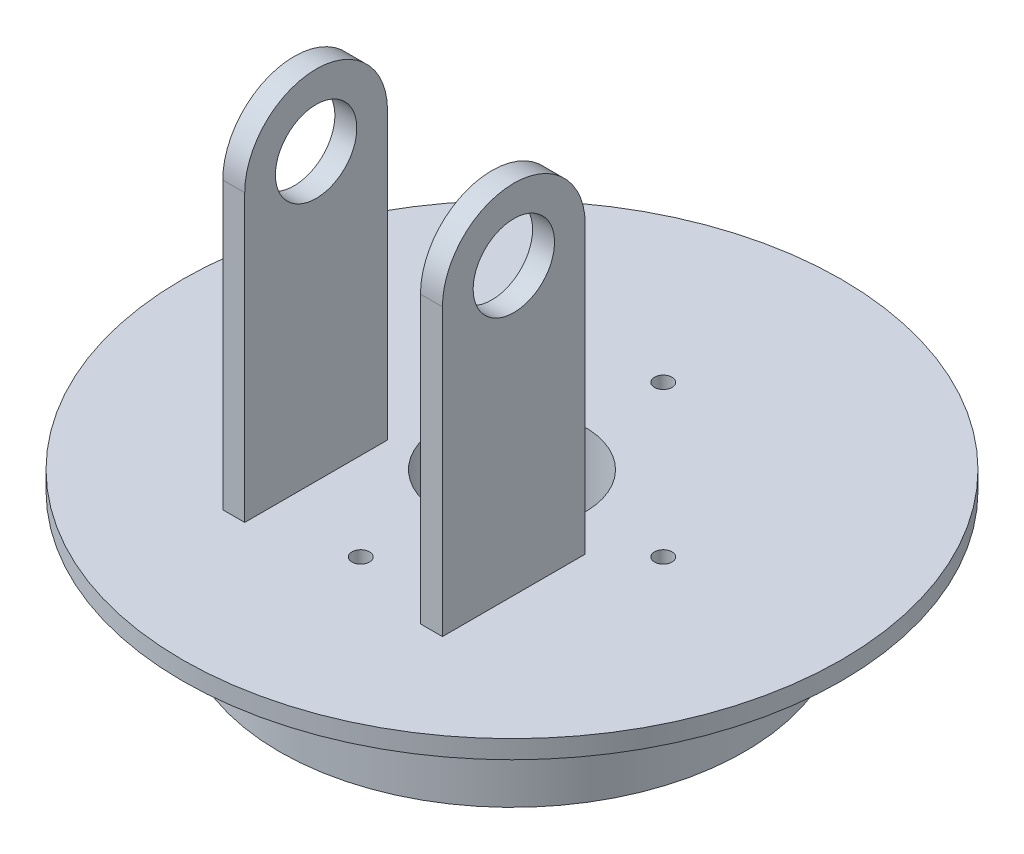
from build123d import *

# Parameters (mm, degrees)
SKETCH_1_R          = 90
EXTRUDE_2_DEPTH     = 5
SKETCH_2_R          = 63.5
EXTRUDE_3_DEPTH     = 30
SKETCH_3_R          = 2.415
CUT_EXTRUDE_1_DEPTH = 36
SKETCH_4_W          = 6
SKETCH_4_H          = 39
EXTRUDE_4_DEPTH     = 78
EXTRUDE_START       = -6
EXTRUDE_5_DEPTH     = 6
EXTRUDE_6_DEPTH     = 6
SKETCH_8_R          = 11.1125
CUT_EXTRUDE_3_DEPTH = 121
SKETCH2_R           = 20
CUT_EXTRUDE1_DEPTH  = 36


with BuildPart() as part:
    # 草圖1 → 填料-伸長2 (new body)
    with BuildSketch(Plane(origin=(0, 0, 0), x_dir=(1, 0, 0), z_dir=(0, 1, 0))):
        Circle(SKETCH_1_R)
    extrude(amount=EXTRUDE_2_DEPTH)

    # 草圖2 → 填料-伸長3 (add)
    with BuildSketch(Plane.XZ):
        Circle(SKETCH_2_R)
    extrude(amount=EXTRUDE_3_DEPTH)

    # 草圖3 → 除料-伸長1 (cut, through all)
    with BuildSketch(Plane(origin=(0, 5, 0), x_dir=(1, 0, 0), z_dir=(0, 1, 0))):
        with Locations((0, 41.31)):
            Circle(SKETCH_3_R)
        with Locations((0, -41.31)):
            Circle(SKETCH_3_R)
        with Locations((-41.31, 0)):
            Circle(SKETCH_3_R)
        with Locations((41.31, 0)):
            Circle(SKETCH_3_R)
    extrude(amount=-CUT_EXTRUDE_1_DEPTH, mode=Mode.SUBTRACT)

    # 草圖4 → 填料-伸長4 (add)
    with BuildSketch(Plane(origin=(0, 5, 0), x_dir=(1, 0, 0), z_dir=(0, 1, 0))):
        with Locations((-27, -29.5)):
            Rectangle(SKETCH_4_W, SKETCH_4_H)
        with Locations((27, -29.5)):
            Rectangle(SKETCH_4_W, SKETCH_4_H)
    extrude(amount=EXTRUDE_4_DEPTH)

    # 草圖5 → 填料-伸長5 (add)
    with BuildSketch(Plane.ZY.offset(30).offset(EXTRUDE_START)):
        with BuildLine():
            Line((10, 83), (49, 83))
            ThreePointArc((49, 83), (29.5, 102.5), (10, 83))
        make_face()
    extrude(amount=EXTRUDE_5_DEPTH)

    # 草圖7 → 填料-伸長6 (add)
    with BuildSketch(Plane.ZY.offset(-24)):
        with BuildLine():
            Line((10, 83), (49, 83))
            ThreePointArc((49, 83), (29.5, 102.5), (10, 83))
        make_face()
    extrude(amount=-EXTRUDE_6_DEPTH)

    # 草圖8 → 除料-伸長3 (cut, through all)
    with BuildSketch(Plane.ZY.offset(30)):
        with Locations((29.5, 83)):
            Circle(SKETCH_8_R)
    extrude(amount=-CUT_EXTRUDE_3_DEPTH, mode=Mode.SUBTRACT)

    # Sketch2 → Cut-Extrude1 (cut, through all)
    with BuildSketch(Plane(origin=(0, 5, 0), x_dir=(1, 0, 0), z_dir=(0, 1, 0))):
        Circle(SKETCH2_R)
    extrude(amount=-CUT_EXTRUDE1_DEPTH, mode=Mode.SUBTRACT)


solid = part.part
